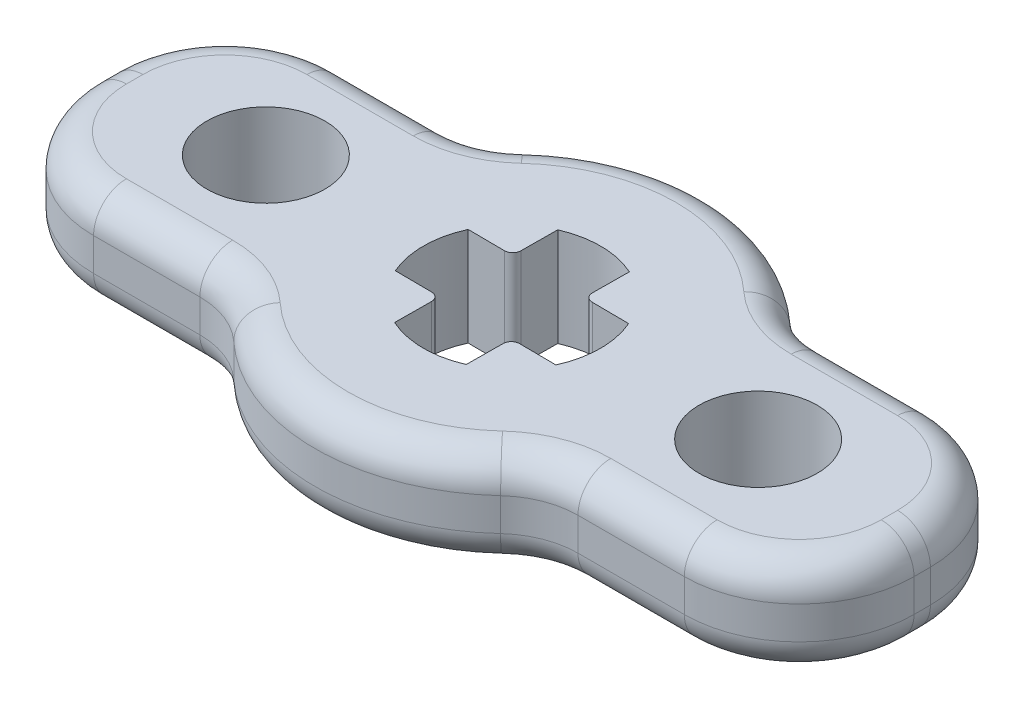
from build123d import *

# Parameters (mm, degrees)
SKETCH1_W            = 25
SKETCH1_H            = 7.5
BOSS_EXTRUDE1_DEPTH  = 3
CUT_EXTRUDE2_DEPTH   = 4
BOSS_EXTRUDE2_DEPTH  = 3
FILLET8_R            = 2.5
FILLET4_R            = 3.5
M3_CLEARANCE_HOLE1_D = 3.6
FILLET6_R            = 1
FILLET7_R            = 0.25


with BuildPart() as part:
    # Sketch1 → Boss-Extrude1 (new body)
    with BuildSketch(Plane(origin=(0, 0, 0), x_dir=(1, 0, 0), z_dir=(0, 1, 0))):
        Rectangle(SKETCH1_W, SKETCH1_H)
    extrude(amount=BOSS_EXTRUDE1_DEPTH)

    # Sketch1_3 → Cut-Extrude2 (cut, through all)
    with BuildSketch(Plane(origin=(0, 0, 0), x_dir=(1, 0, 0), z_dir=(0, 1, 0))):
        with BuildLine():
            Line((2.456770065, -1.119946806), (1.091049314, -1.10887844))
            Line((1.091049314, -1.10887844), (1.079980948, -2.47459919))
            ThreePointArc((1.079980948, -2.47459919), (-0.021881199, -2.699911334), (-1.119946806, -2.456770065))
            Line((-1.119946806, -2.456770065), (-1.10887844, -1.091049314))
            Line((-1.10887844, -1.091049314), (-2.47459919, -1.079980948))
            ThreePointArc((-2.47459919, -1.079980948), (-2.699911334, 0.021881199), (-2.456770065, 1.119946806))
            Line((-2.456770065, 1.119946806), (-1.091049314, 1.10887844))
            Line((-1.091049314, 1.10887844), (-1.079980948, 2.47459919))
            ThreePointArc((-1.079980948, 2.47459919), (0.021881199, 2.699911334), (1.119946806, 2.456770065))
            Line((1.119946806, 2.456770065), (1.10887844, 1.091049314))
            Line((1.10887844, 1.091049314), (2.47459919, 1.079980948))
            ThreePointArc((2.47459919, 1.079980948), (2.699911334, -0.021881199), (2.456770065, -1.119946806))
        make_face()
        with BuildLine():
            ThreePointArc((-0.818311322, -2.256184075), (-0.019449955, -2.399921186), (0.781636135, -2.269150712))
            Line((0.781636135, -2.269150712), (0.79349041, -0.806457047))
            Line((0.79349041, -0.806457047), (2.256184075, -0.818311322))
            ThreePointArc((2.256184075, -0.818311322), (2.399921186, -0.019449955), (2.269150712, 0.781636135))
            Line((2.269150712, 0.781636135), (0.806457047, 0.79349041))
            Line((0.806457047, 0.79349041), (0.818311322, 2.256184075))
            ThreePointArc((0.818311322, 2.256184075), (0.019449955, 2.399921186), (-0.781636135, 2.269150712))
            Line((-0.781636135, 2.269150712), (-0.79349041, 0.806457047))
            Line((-0.79349041, 0.806457047), (-2.256184075, 0.818311322))
            ThreePointArc((-2.256184075, 0.818311322), (-2.399921186, 0.019449955), (-2.269150712, -0.781636135))
            Line((-2.269150712, -0.781636135), (-0.806457047, -0.79349041))
            Line((-0.806457047, -0.79349041), (-0.818311322, -2.256184075))
        make_face(mode=Mode.SUBTRACT)
        with BuildLine():
            Line((-0.818311322, -2.256184075), (-0.806457047, -0.79349041))
            Line((-0.806457047, -0.79349041), (-2.269150712, -0.781636135))
            ThreePointArc((-2.269150712, -0.781636135), (-2.399921186, 0.019449955), (-2.256184075, 0.818311322))
            Line((-2.256184075, 0.818311322), (-0.79349041, 0.806457047))
            Line((-0.79349041, 0.806457047), (-0.781636135, 2.269150712))
            ThreePointArc((-0.781636135, 2.269150712), (0.019449955, 2.399921186), (0.818311322, 2.256184075))
            Line((0.818311322, 2.256184075), (0.806457047, 0.79349041))
            Line((0.806457047, 0.79349041), (2.269150712, 0.781636135))
            ThreePointArc((2.269150712, 0.781636135), (2.399921186, -0.019449955), (2.256184075, -0.818311322))
            Line((2.256184075, -0.818311322), (0.79349041, -0.806457047))
            Line((0.79349041, -0.806457047), (0.781636135, -2.269150712))
            ThreePointArc((0.781636135, -2.269150712), (-0.019449955, -2.399921186), (-0.818311322, -2.256184075))
        make_face()
    extrude(amount=CUT_EXTRUDE2_DEPTH, mode=Mode.SUBTRACT)

    # Sketch4 → Boss-Extrude2 (add)
    with BuildSketch(Plane(origin=(0, 0, 0), x_dir=(1, 0, 0), z_dir=(0, 1, 0))):
        with BuildLine():
            Line((-4.683748499, 3.75), (4.683748499, 3.75))
            ThreePointArc((4.683748499, 3.75), (0, 6), (-4.683748499, 3.75))
        make_face()
        with BuildLine():
            ThreePointArc((-4.683748499, -3.75), (0, -6), (4.683748499, -3.75))
            Line((4.683748499, -3.75), (-4.683748499, -3.75))
        make_face()
    extrude(amount=BOSS_EXTRUDE2_DEPTH)

    # Fillet8
    fillet8_edges = [part.edges().sort_by_distance(p)[0] for p in [
        (-4.683748499, 1.5, -3.75),
        (4.683748499, 1.5, -3.75),
        (4.683748499, 1.5, 3.75),
        (-4.683748499, 1.5, 3.75),
    ]]
    fillet(fillet8_edges, radius=FILLET8_R)

    # Fillet4
    fillet4_edges = [part.edges().sort_by_distance(p)[0] for p in [
        (-12.5, 1.5, 3.75),
        (-12.5, 1.5, -3.75),
        (12.5, 1.5, 3.75),
        (12.5, 1.5, -3.75),
    ]]
    fillet(fillet4_edges, radius=FILLET4_R)

    # M3 Clearance Hole1 (through all)
    with Locations(Plane.XZ):
        with Locations((-7.5, 0), (7.5, 0)):
            Hole(M3_CLEARANCE_HOLE1_D / 2)

    # Fillet6
    fillet6_edges = [part.edges().sort_by_distance(p)[0] for p in [
        (0, 3, 6),
        (0, 0, 6),
        (7.380429655, 0, 3.75),
        (7.380429655, 3, 3.75),
        (0, 3, -6),
        (0, 0, -6),
        (7.380429655, 0, -3.75),
        (7.380429655, 3, -3.75),
        (-4.851350717, 0, 3.921310644),
        (-4.851350717, 3, 3.921310644),
        (4.851350717, 0, 3.921310644),
        (4.851350717, 3, 3.921310644),
        (4.851350717, 0, -3.921310644),
        (4.851350717, 3, -3.921310644),
        (-4.851350717, 0, -3.921310644),
        (-4.851350717, 3, -3.921310644),
        (-7.380429655, 0, 3.75),
        (-12.5, 0, 0),
        (-7.380429655, 0, -3.75),
        (12.5, 0, 0),
        (-11.474873734, 0, -2.724873734),
        (-11.474873734, 0, 2.724873734),
        (11.474873734, 0, 2.724873734),
        (11.474873734, 0, -2.724873734),
        (12.5, 3, 0),
        (-7.380429655, 3, 3.75),
        (-7.380429655, 3, -3.75),
        (-12.5, 3, 0),
        (-11.474873734, 3, -2.724873734),
        (-11.474873734, 3, 2.724873734),
        (11.474873734, 3, 2.724873734),
        (11.474873734, 3, -2.724873734),
    ]]
    fillet(fillet6_edges, radius=FILLET6_R)

    # Fillet7
    fillet7_edges = [part.edges().sort_by_distance(p)[0] for p in [
        (1.091049314, 1.5, 1.10887844),
        (1.10887844, 1.5, -1.091049314),
        (-1.091049314, 1.5, -1.10887844),
        (-1.10887844, 1.5, 1.091049314),
    ]]
    fillet(fillet7_edges, radius=FILLET7_R)


solid = part.part
